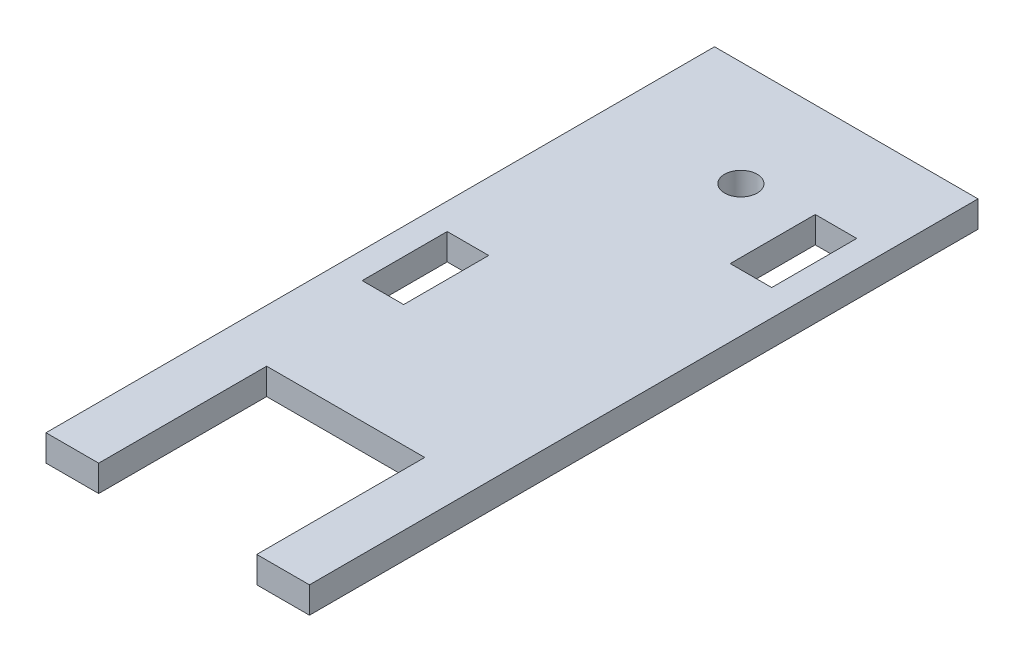
from build123d import *

# Parameters (mm, degrees)
SKETCH1_R           = 7.874
SKETCH1_W           = 25.4
SKETCH1_H           = 80.9625
BOSS_EXTRUDE1_DEPTH = 12.7
SKETCH2_W           = 20
SKETCH2_H           = 41
CUT_EXTRUDE1_DEPTH  = 13.7
SKETCH3_W           = 20
SKETCH3_H           = 41
CUT_EXTRUDE2_DEPTH  = 13.7


with BuildPart() as part:
    # Sketch1 → Boss-Extrude1 (new body)
    with BuildSketch(Plane(origin=(0, 0, 0), x_dir=(1, 0, 0), z_dir=(0, 1, 0))):
        Polygon((0, 241.3), (0, 0), (25.4, 0), (101.6, 0), (127, 0), (127, 241.3), align=None)
        with Locations((63.5, 190.5)):
            Circle(SKETCH1_R, mode=Mode.SUBTRACT)
        with Locations((12.7, -40.48125)):
            Rectangle(SKETCH1_W, SKETCH1_H)
        with Locations((114.3, -40.48125)):
            Rectangle(SKETCH1_W, SKETCH1_H)
    extrude(amount=BOSS_EXTRUDE1_DEPTH)

    # Sketch2 → Cut-Extrude1 (cut, through all)
    with BuildSketch(Plane.XZ):
        with Locations((104.3, -175.05319538)):
            Rectangle(SKETCH2_W, SKETCH2_H)
    extrude(amount=-CUT_EXTRUDE1_DEPTH, mode=Mode.SUBTRACT)

    # Sketch3 → Cut-Extrude2 (cut, through all)
    with BuildSketch(Plane(origin=(0, 0, 0), x_dir=(-1, 0, 0), z_dir=(0, -1, 0))):
        with Locations((-22.7, 79.2375)):
            Rectangle(SKETCH3_W, SKETCH3_H)
    extrude(amount=-CUT_EXTRUDE2_DEPTH, mode=Mode.SUBTRACT)


solid = part.part
